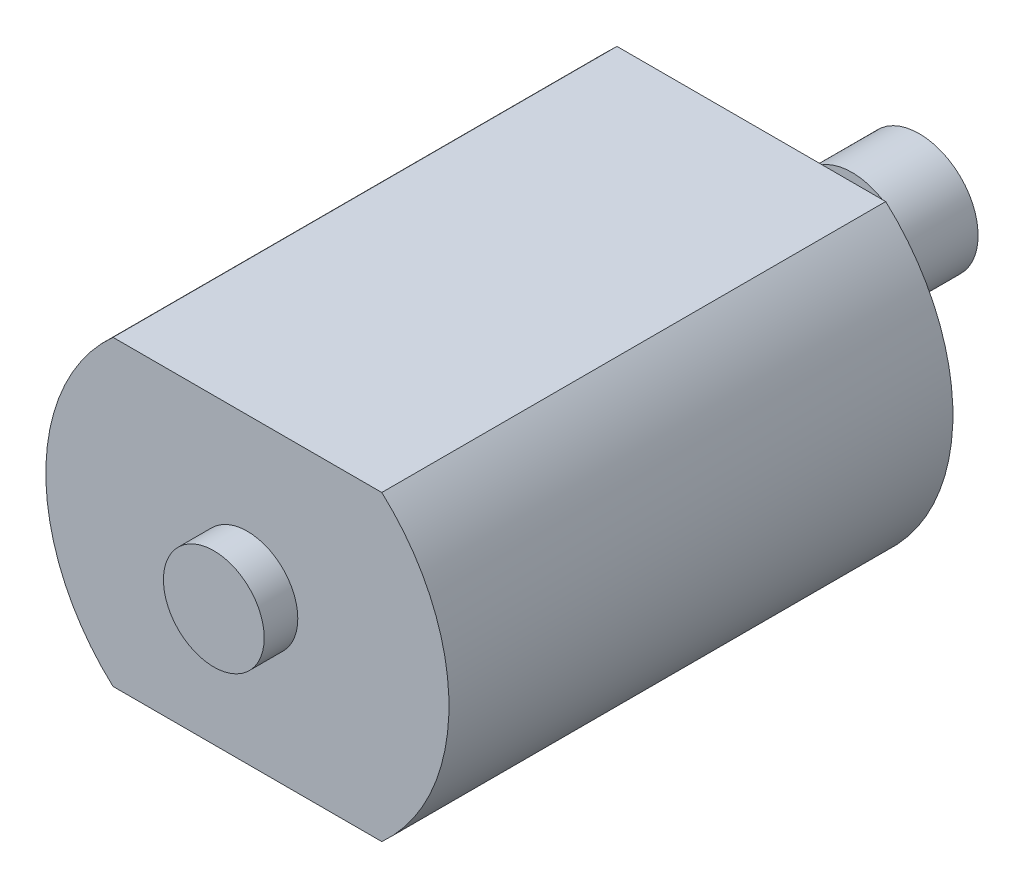
from build123d import *

# Parameters (mm, degrees)
SKETCH1_W           = 16
SKETCH1_H           = 30
BOSS_EXTRUDE1_DEPTH = 9
SKETCH2_R           = 3
BOSS_EXTRUDE2_DEPTH = 1
SKETCH3_R           = 3
BOSS_EXTRUDE3_DEPTH = 2
BOSS_EXTRUDE4_DEPTH = 30
SKETCH6_R           = 0.75
BOSS_EXTRUDE5_DEPTH = 10
SKETCH7_R           = 3.5
BOSS_EXTRUDE6_DEPTH = 4


with BuildPart() as part:
    # Sketch1 → Boss-Extrude1 (new body, symmetric)
    with BuildSketch(Plane(origin=(0, 0, 0), x_dir=(1, 0, 0), z_dir=(0, 1, 0))):
        with Locations((0, -15)):
            Rectangle(SKETCH1_W, SKETCH1_H)
    extrude(amount=BOSS_EXTRUDE1_DEPTH, both=True)

    # Sketch2 → Boss-Extrude2 (add)
    with BuildSketch(Plane(origin=(0, 0, 0), x_dir=(-1, 0, 0), z_dir=(0, 0, -1))):
        Circle(SKETCH2_R)
    extrude(amount=BOSS_EXTRUDE2_DEPTH)

    # Sketch3 → Boss-Extrude3 (add)
    with BuildSketch(Plane.XY.offset(30)):
        Circle(SKETCH3_R)
    extrude(amount=BOSS_EXTRUDE3_DEPTH)

    # Sketch5 → Boss-Extrude4 (add)
    with BuildSketch(Plane.XY):
        with BuildLine():
            Line((8, 9), (8, -9))
            ThreePointArc((8, -9), (12, 0), (8, 9))
        make_face()
        with BuildLine():
            Line((-8, 9), (-8, -9))
            ThreePointArc((-8, -9), (-12, 0), (-8, 9))
        make_face()
    extrude(amount=BOSS_EXTRUDE4_DEPTH)

    # Sketch6 → Boss-Extrude5 (add)
    with BuildSketch(Plane(origin=(0, 0, 0), x_dir=(-1, 0, 0), z_dir=(0, 0, -1))):
        Circle(SKETCH6_R)
    extrude(amount=BOSS_EXTRUDE5_DEPTH)

    # Sketch7 → Boss-Extrude6 (add)
    with BuildSketch(Plane(origin=(0, 0, -10), x_dir=(-1, 0, 0), z_dir=(0, 0, -1))):
        Circle(SKETCH7_R)
    extrude(amount=-BOSS_EXTRUDE6_DEPTH)


solid = part.part
